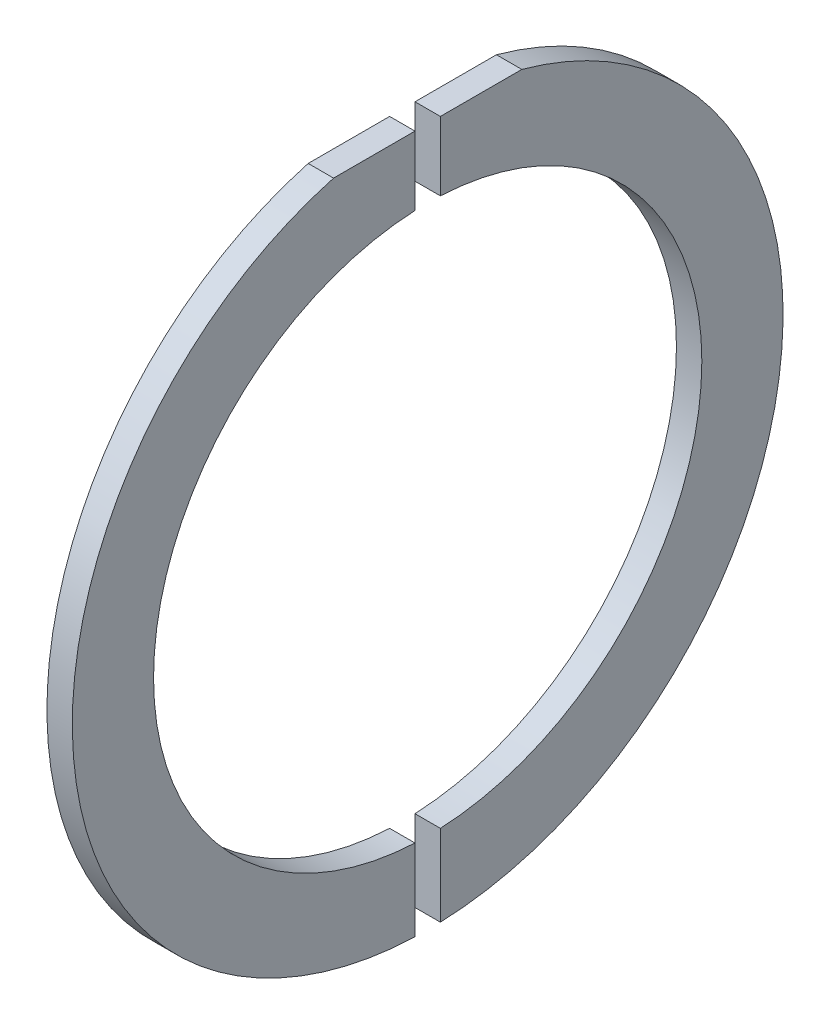
from build123d import *

# Parameters (mm, degrees)
SKETCH_1_W          = 2
SKETCH_1_H          = 6.4
CUT_EXTRUDE_1_DEPTH = 3


with BuildPart() as part:
    # Эскиз1 → Повернуть1 (revolve)
    with BuildSketch(Plane(origin=(0, 0, 0), x_dir=(1, 0, 0), z_dir=(0, 1, 0))):
        with Locations((-1, 24.8)):
            Rectangle(SKETCH_1_W, SKETCH_1_H)
    revolve(axis=Axis((-20.865906448, 0, 0), (1, 0, 0)))

    # Эскиз2 → Вырез-Вытянуть1 (cut, through all)
    with BuildSketch(Plane(origin=(0, 0, 0), x_dir=(0, 0, -1), z_dir=(1, 0, 0))):
        with BuildLine():
            ThreePointArc((-1, -27.982137159), (0, -28), (1, -27.982137159))
            Line((1, -27.982137159), (1, -21.576839435))
            ThreePointArc((1, -21.576839435), (0, -21.6), (-1, -21.576839435))
            Line((-1, -21.576839435), (-1, -27.982137159))
        make_face()
        with BuildLine():
            ThreePointArc((-1, 21.576839435), (0, 21.6), (1, 21.576839435))
            Line((1, 21.576839435), (1, 27))
            Line((1, 27), (7.416198487, 27))
            ThreePointArc((7.416198487, 27), (0, 28), (-7.416198487, 27))
            Line((-7.416198487, 27), (-1, 27))
            Line((-1, 27), (-1, 21.576839435))
        make_face()
    extrude(amount=-CUT_EXTRUDE_1_DEPTH, mode=Mode.SUBTRACT)


solid = part.part
